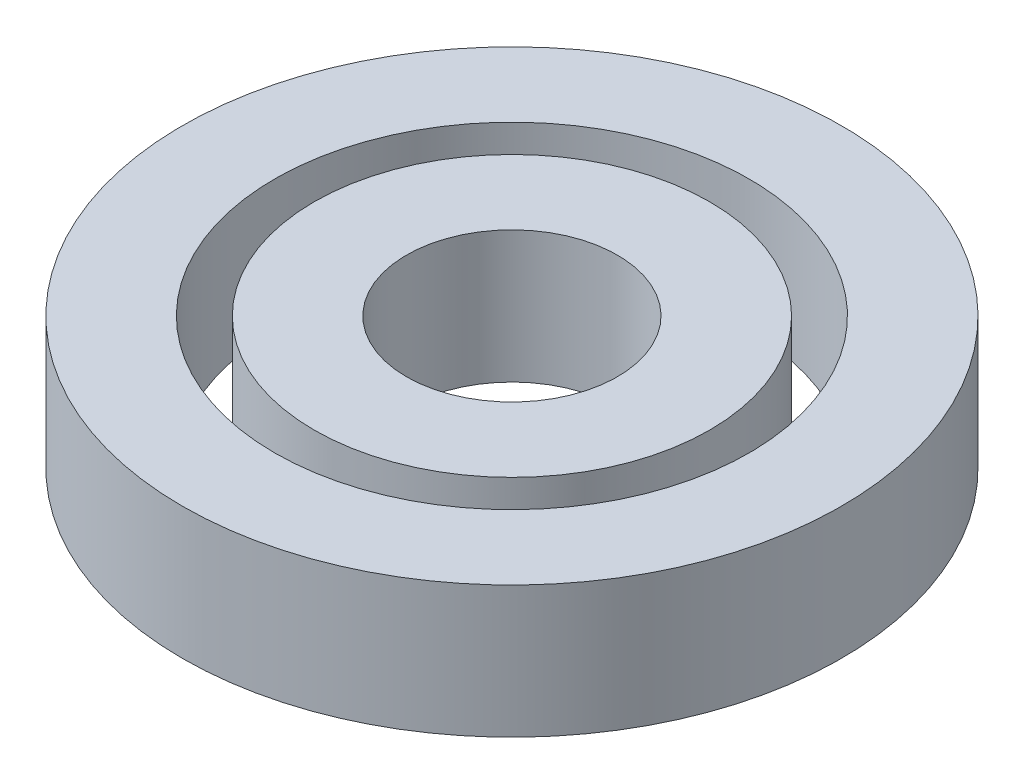
from build123d import *

# Parameters (mm, degrees)
SKETCH1_R           = 7.5
SKETCH1_R_2         = 4
BOSS_EXTRUDE1_DEPTH = 5
SKETCH2_R           = 12.5
SKETCH2_R_2         = 9
BOSS_EXTRUDE2_DEPTH = 5


with BuildPart() as part:
    # Sketch1 → Boss-Extrude1 (new body)
    with BuildSketch(Plane(origin=(0, 0, 0), x_dir=(1, 0, 0), z_dir=(0, 1, 0))):
        Circle(SKETCH1_R)
        Circle(SKETCH1_R_2, mode=Mode.SUBTRACT)
    extrude(amount=BOSS_EXTRUDE1_DEPTH)


with BuildPart() as body_2:
    # Sketch2 → Boss-Extrude2 (new body)
    with BuildSketch(Plane(origin=(0, 0, 0), x_dir=(1, 0, 0), z_dir=(0, 1, 0))):
        Circle(SKETCH2_R)
        Circle(SKETCH2_R_2, mode=Mode.SUBTRACT)
    extrude(amount=BOSS_EXTRUDE2_DEPTH)


solid = Compound([part.part, body_2.part])
